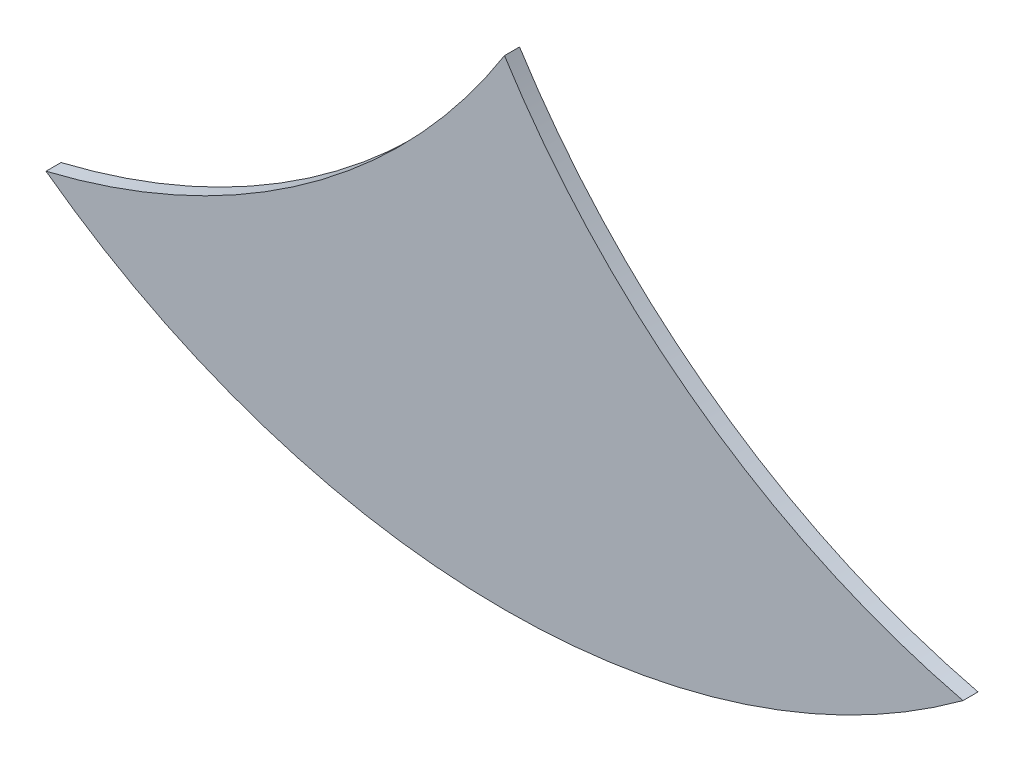
from build123d import *

# Parameters (mm, degrees)
SALIENTE_EXTRUIR1_DEPTH = 0.1


with BuildPart() as part:
    # Model → Saliente-Extruir1 (new body)
    with BuildSketch(Plane.XY):
        with BuildLine():
            ThreePointArc((31.528738572, 18.113579097), (34.576, 17.113361897), (37.623261428, 18.113579097))
            ThreePointArc((37.623261428, 18.113579097), (35.886250929, 18.911075041), (34.576, 20.302638103))
            ThreePointArc((34.576, 20.302638103), (33.265749071, 18.911075041), (31.528738572, 18.113579097))
        make_face()
    extrude(amount=SALIENTE_EXTRUIR1_DEPTH)


solid = part.part
